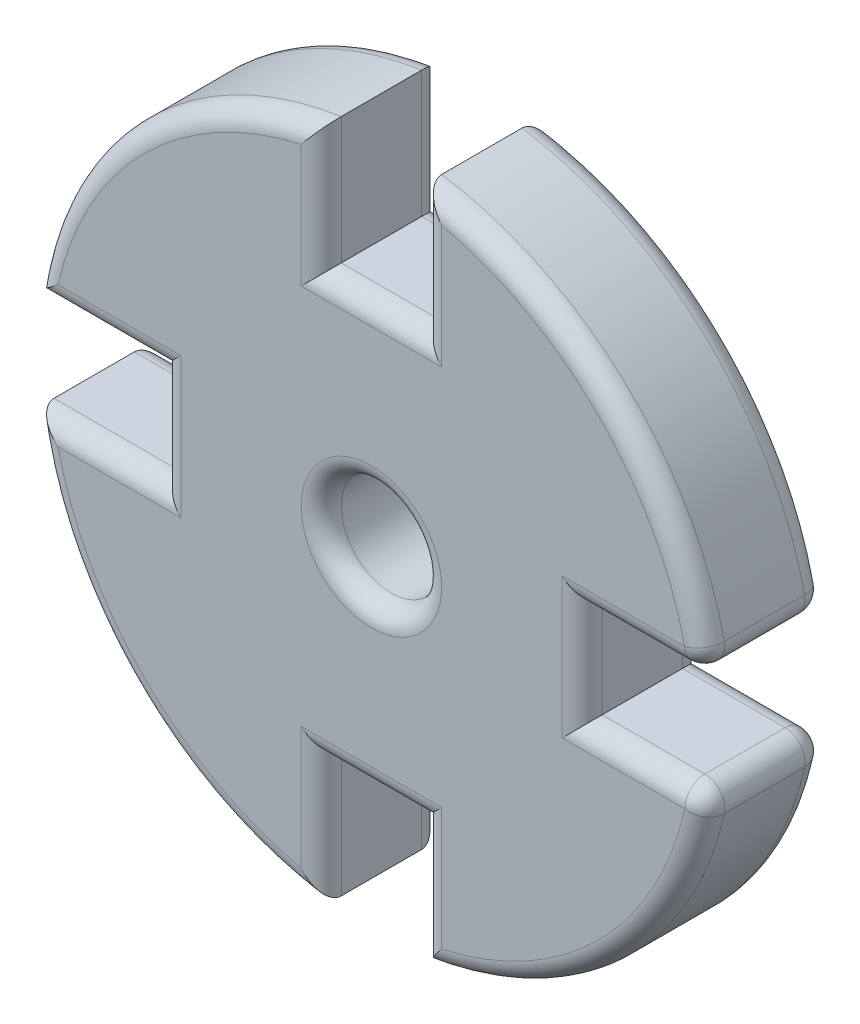
from build123d import *

# Parameters (mm, degrees)
SKETCH1_R      = 2.5
EXTRUDE1_DEPTH = 6
FILLET1_R      = 1


with BuildPart() as part:
    # Sketch1 → Extrude1 (new body)
    with BuildSketch(Plane.XY):
        with BuildLine():
            Line((2.5, 16.815171721), (2.5, 10.5))
            Line((2.5, 10.5), (-2.5, 10.5))
            Line((-2.5, 10.5), (-2.5, 16.815171721))
            ThreePointArc((-2.5, 16.815171721), (-12.02081528, 12.02081528), (-16.815171721, 2.5))
            Line((-16.815171721, 2.5), (-10.5, 2.5))
            Line((-10.5, 2.5), (-10.5, -2.5))
            Line((-10.5, -2.5), (-16.815171721, -2.5))
            ThreePointArc((-16.815171721, -2.5), (-12.02081528, -12.02081528), (-2.5, -16.815171721))
            Line((-2.5, -16.815171721), (-2.5, -10.5))
            Line((-2.5, -10.5), (2.5, -10.5))
            Line((2.5, -10.5), (2.5, -16.815171721))
            ThreePointArc((2.5, -16.815171721), (12.02081528, -12.02081528), (16.815171721, -2.5))
            Line((16.815171721, -2.5), (10.5, -2.5))
            Line((10.5, -2.5), (10.5, 2.5))
            Line((10.5, 2.5), (16.815171721, 2.5))
            ThreePointArc((16.815171721, 2.5), (12.02081528, 12.02081528), (2.5, 16.815171721))
        make_face()
        Circle(SKETCH1_R, mode=Mode.SUBTRACT)
    extrude(amount=EXTRUDE1_DEPTH)

    # Fillet1
    fillet1_edges = [part.edges().sort_by_distance(p)[0] for p in [
        (13.65758586, 2.5, 6),
        (12.02081528, 12.02081528, 6),
        (10.5, 0, 0),
        (13.65758586, -2.5, 0),
        (12.02081528, -12.02081528, 0),
        (2.5, 13.65758586, 6),
        (2.5, -13.65758586, 0),
        (0, -10.5, 0),
        (-2.5, -13.65758586, 0),
        (-12.02081528, -12.02081528, 0),
        (-13.65758586, -2.5, 0),
        (-10.5, 0, 0),
        (-13.65758586, 2.5, 0),
        (-12.02081528, 12.02081528, 0),
        (0, 10.5, 6),
        (-2.5, 13.65758586, 0),
        (0, 10.5, 0),
        (2.5, 13.65758586, 0),
        (12.02081528, 12.02081528, 0),
        (13.65758586, 2.5, 0),
        (-2.5, 0, 0),
        (-2.5, 13.65758586, 6),
        (-12.02081528, 12.02081528, 6),
        (16.815171721, -2.5, 3),
        (16.815171721, 2.5, 3),
        (-13.65758586, 2.5, 6),
        (-10.5, 0, 6),
        (-13.65758586, -2.5, 6),
        (-12.02081528, -12.02081528, 6),
        (-2.5, -13.65758586, 6),
        (0, -10.5, 6),
        (2.5, -13.65758586, 6),
        (-2.5, 0, 6),
        (12.02081528, -12.02081528, 6),
        (13.65758586, -2.5, 6),
        (10.5, 0, 6),
    ]]
    fillet(fillet1_edges, radius=FILLET1_R)


solid = part.part
